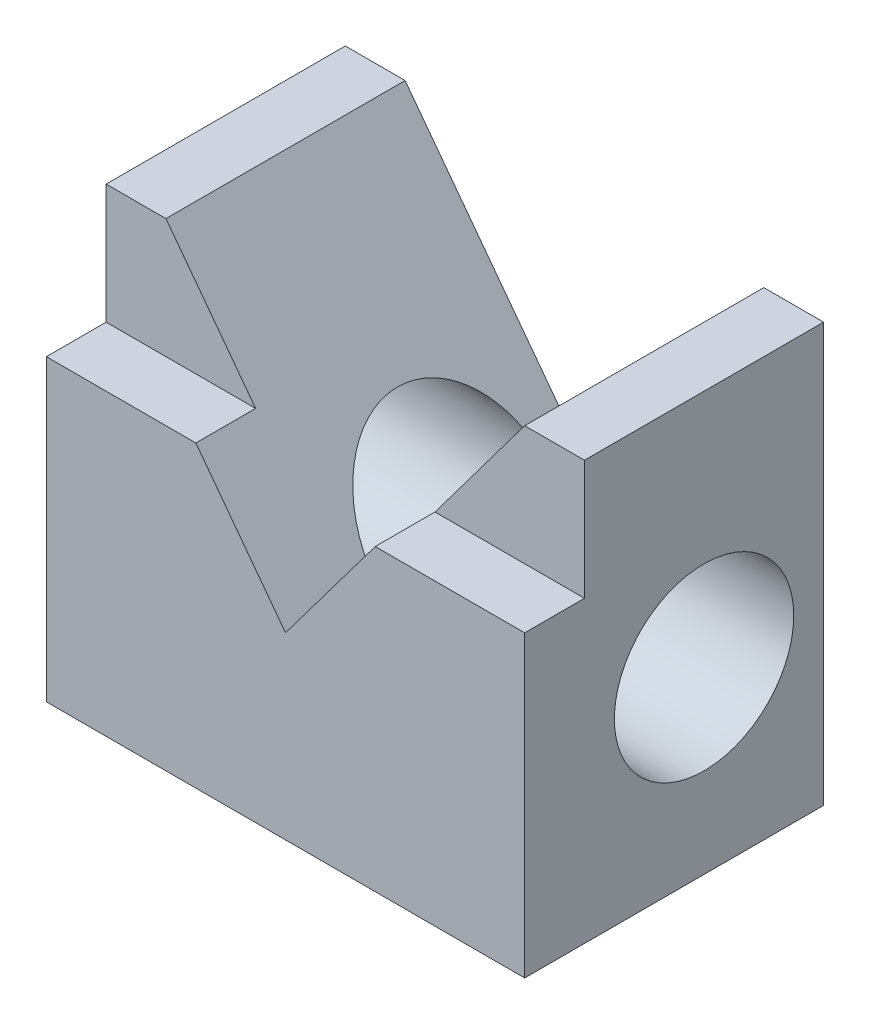
from build123d import *

# Parameters (mm, degrees)
BOSS_EXTRUDE1_DEPTH = 63.5
SKETCH2_R           = 19.05
CUT_EXTRUDE1_DEPTH  = 102.6
CUT_EXTRUDE2_DEPTH  = 12.7


with BuildPart() as part:
    # Sketch1 → Boss-Extrude1 (new body)
    with BuildSketch(Plane.XY):
        Polygon((0, 0), (0, 88.9), (12.7, 88.9), (50.8, 38.1), (88.9, 88.9), (101.6, 88.9), (101.6, 0), align=None)
    extrude(amount=BOSS_EXTRUDE1_DEPTH)

    # Sketch2 → Cut-Extrude1 (cut, through all)
    with BuildSketch(Plane(origin=(0, 0, 0), x_dir=(0, 0, -1), z_dir=(1, 0, 0))):
        with Locations((-25.4, 38.1)):
            Circle(SKETCH2_R)
    extrude(amount=CUT_EXTRUDE1_DEPTH, mode=Mode.SUBTRACT)

    # Sketch3 → Cut-Extrude2 (cut)
    with BuildSketch(Plane.XY.offset(63.5)):
        Polygon((0, 63.5), (31.75, 63.5), (12.7, 88.9), (0, 88.9), align=None)
        Polygon((69.85, 63.5), (101.6, 63.5), (101.6, 88.9), (88.9, 88.9), align=None)
    extrude(amount=-CUT_EXTRUDE2_DEPTH, mode=Mode.SUBTRACT)


solid = part.part
